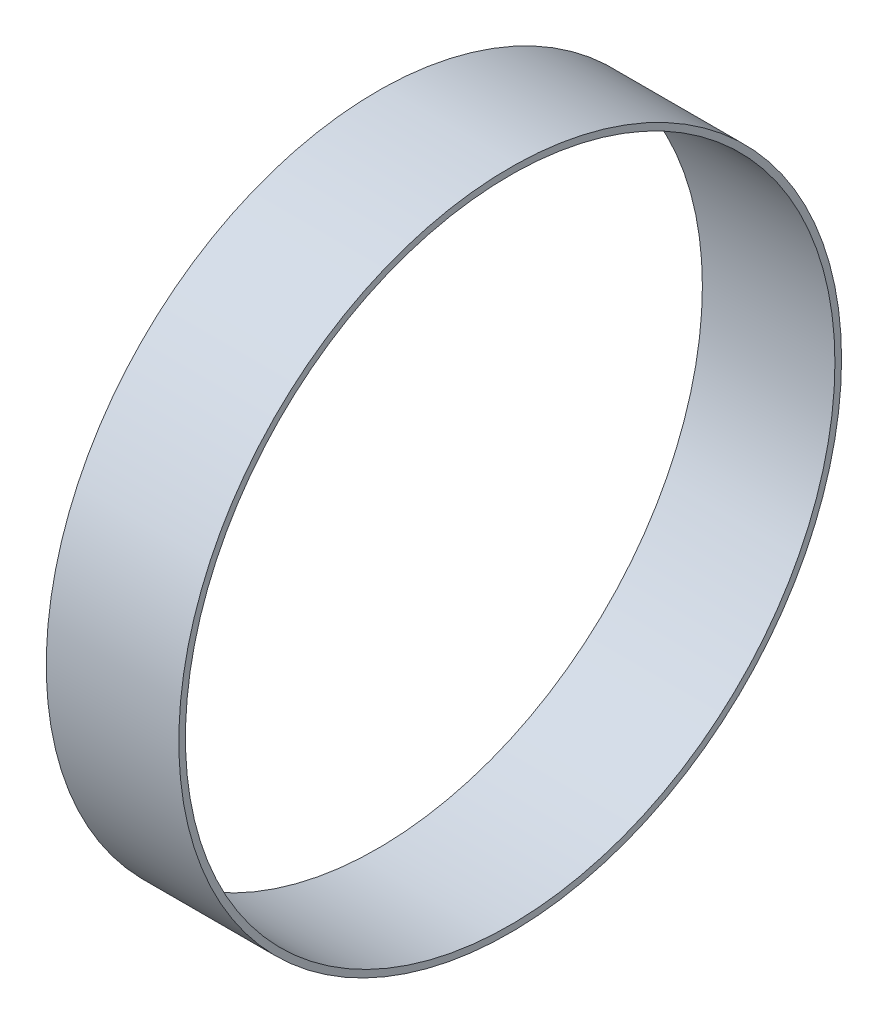
from build123d import *

# Parameters (mm, degrees)
SKETCH1_R           = 25
SKETCH1_R_2         = 24.5
BOSS_EXTRUDE1_DEPTH = 10


with BuildPart() as part:
    # Sketch1 → Boss-Extrude1 (new body)
    with BuildSketch(Plane(origin=(0, 0, 0), x_dir=(0, 0, -1), z_dir=(1, 0, 0))):
        Circle(SKETCH1_R)
        Circle(SKETCH1_R_2, mode=Mode.SUBTRACT)
    extrude(amount=BOSS_EXTRUDE1_DEPTH)


solid = part.part
